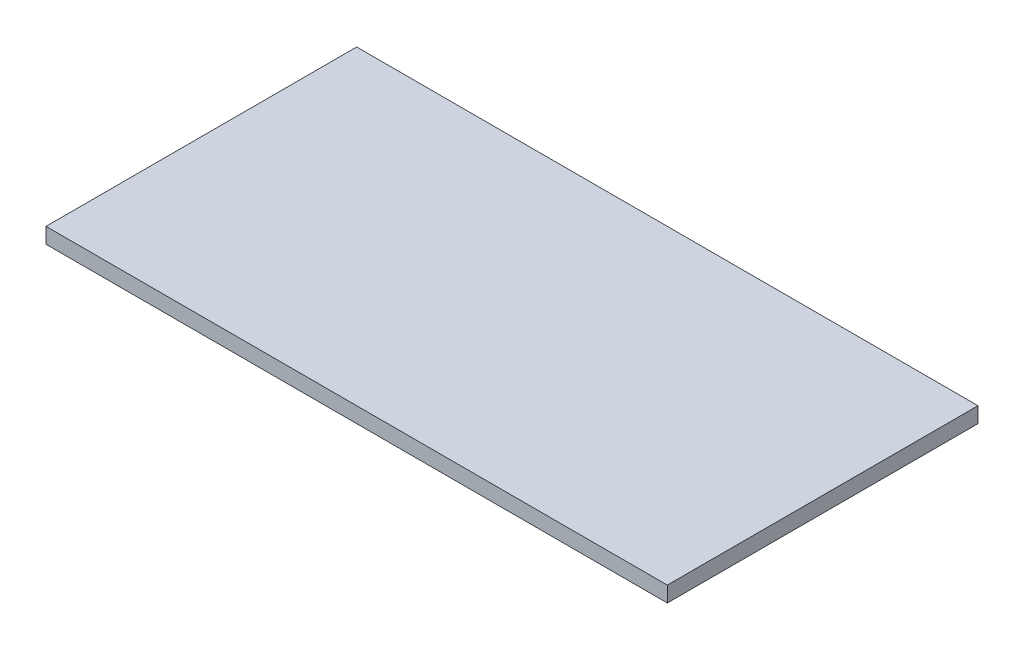
from build123d import *

# Parameters (mm, degrees)
SKETCH1_W           = 200
SKETCH1_H           = 100
BOSS_EXTRUDE1_DEPTH = 5


with BuildPart() as part:
    # Sketch1 → Boss-Extrude1 (new body)
    with BuildSketch(Plane(origin=(0, 0, 0), x_dir=(1, 0, 0), z_dir=(0, 1, 0))):
        Rectangle(SKETCH1_W, SKETCH1_H)
    extrude(amount=BOSS_EXTRUDE1_DEPTH)


solid = part.part
